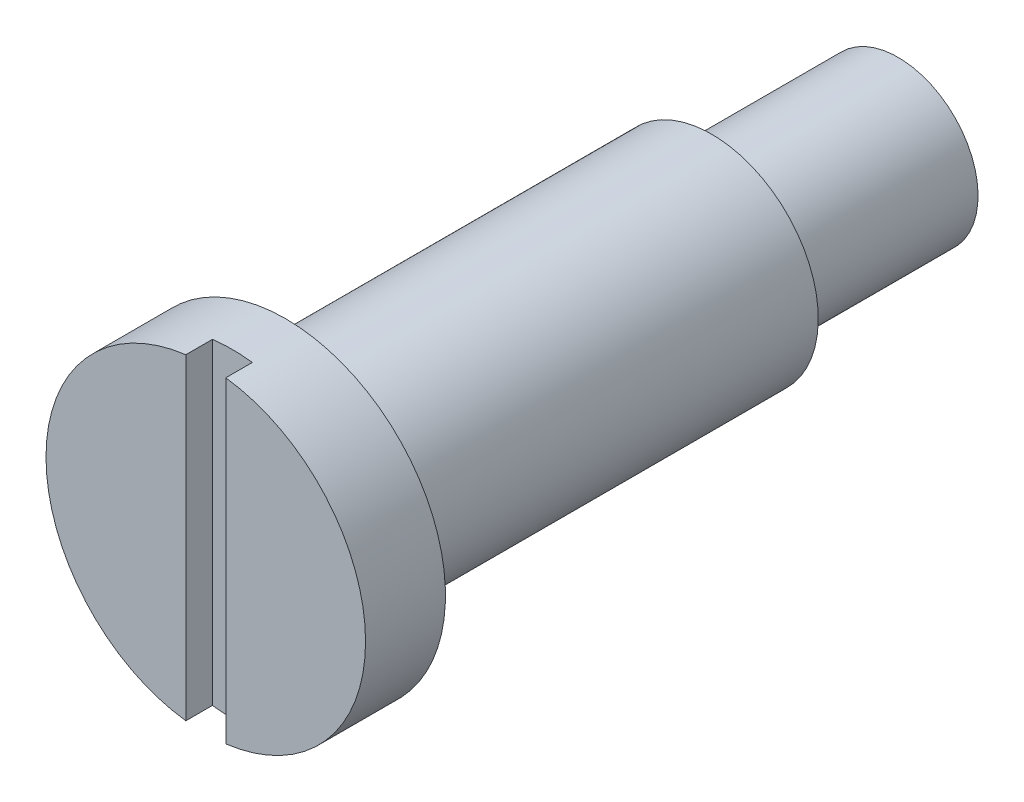
from build123d import *

# Parameters (mm, degrees)
SKETCH_3_W          = 1.5
SKETCH_3_H          = 12
CUT_EXTRUDE_1_DEPTH = 1


with BuildPart() as part:
    # 草图2 → 旋转1 (revolve)
    with BuildSketch(Plane(origin=(0, 0, 0), x_dir=(0, 0, -1), z_dir=(1, 0, 0))):
        Polygon((0, 0), (0, 6), (3, 6), (3, 4), (19, 4), (19, 3), (26, 3), (26, 0), align=None)
    revolve(axis=Axis((0, 0, 0), (0, 0, -1)))

    # 草图3 → 切除-拉伸1 (cut)
    with BuildSketch(Plane.XY):
        Rectangle(SKETCH_3_W, SKETCH_3_H)
    extrude(amount=-CUT_EXTRUDE_1_DEPTH, mode=Mode.SUBTRACT)


solid = part.part
